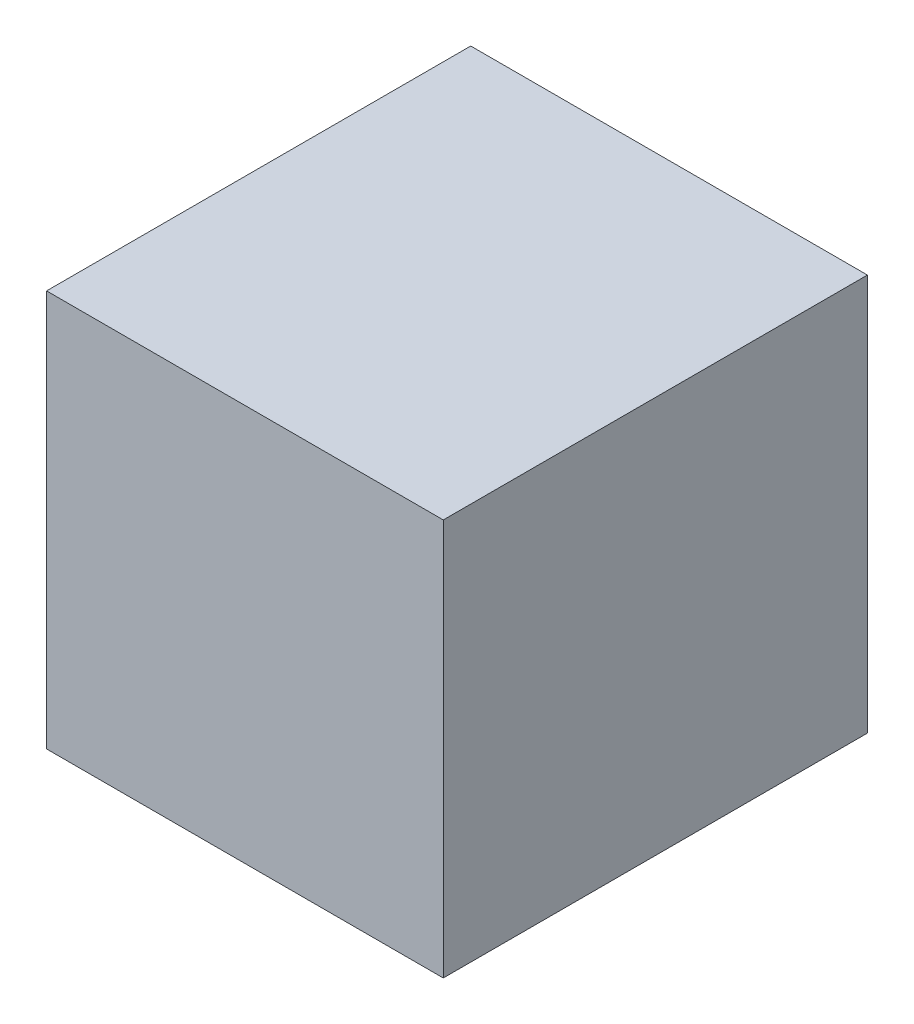
from build123d import *

# Parameters (mm, degrees)
SKETCH1_W           = 31.8
SKETCH1_H           = 31.8
BOSS_EXTRUDE1_DEPTH = 36


with BuildPart() as part:
    # Sketch1 → Boss-Extrude1 (new body)
    with BuildSketch(Plane.XY):
        with Locations((0, 3.7)):
            Rectangle(SKETCH1_W, SKETCH1_H)
    extrude(amount=-BOSS_EXTRUDE1_DEPTH)

    # SurfaceCut1
    split(bisect_by=Plane.XY.offset(-2), keep=Keep.BOTTOM)


solid = part.part
